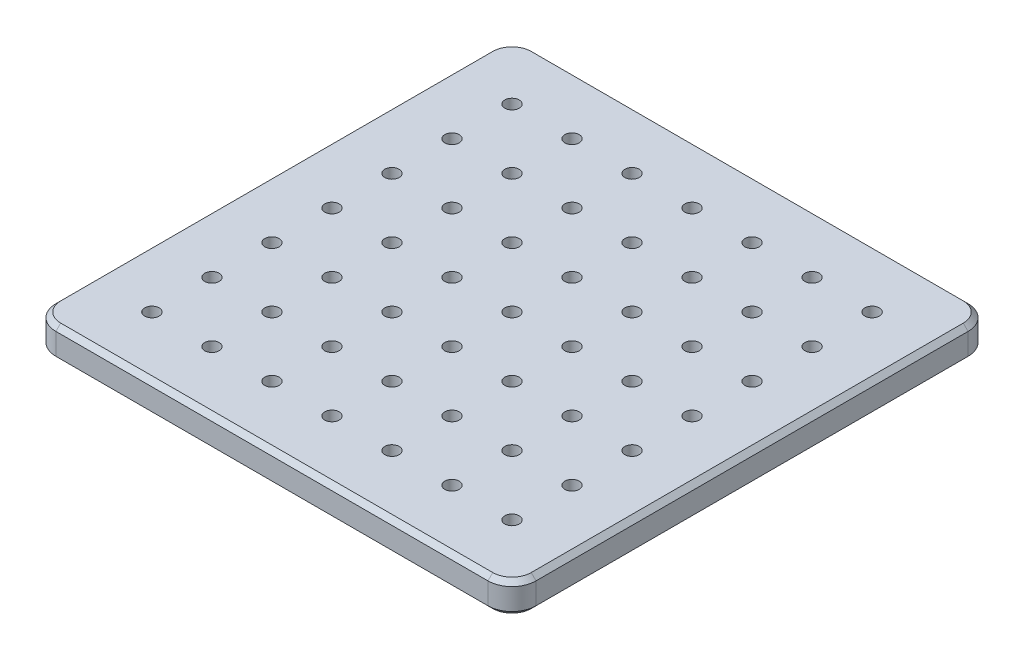
from build123d import *

# Parameters (mm, degrees)
SKETCH_1_R      = 3
EXTRUDE_1_DEPTH = 13
CHAMFER_1_SIZE  = 2


with BuildPart() as part:
    # 草图1 → 凸台-拉伸1 (new body)
    with BuildSketch(Plane(origin=(0, 0, 0), x_dir=(1, 0, 0), z_dir=(0, 1, 0))):
        with BuildLine():
            Line((-90, 100), (90, 100))
            ThreePointArc((90, 100), (97.071067812, 97.071067812), (100, 90))
            Line((100, 90), (100, -90))
            ThreePointArc((100, -90), (97.071067812, -97.071067812), (90, -100))
            Line((90, -100), (-90, -100))
            ThreePointArc((-90, -100), (-97.071067812, -97.071067812), (-100, -90))
            Line((-100, -90), (-100, 90))
            ThreePointArc((-100, 90), (-97.071067812, 97.071067812), (-90, 100))
        make_face()
        with Locations((-75, 75)):
            Circle(SKETCH_1_R, mode=Mode.SUBTRACT)
        with Locations((-50, 75)):
            Circle(SKETCH_1_R, mode=Mode.SUBTRACT)
        with Locations((-25, 75)):
            Circle(SKETCH_1_R, mode=Mode.SUBTRACT)
        with Locations((0, 75)):
            Circle(SKETCH_1_R, mode=Mode.SUBTRACT)
        with Locations((25, 75)):
            Circle(SKETCH_1_R, mode=Mode.SUBTRACT)
        with Locations((50, 75)):
            Circle(SKETCH_1_R, mode=Mode.SUBTRACT)
        with Locations((75, 75)):
            Circle(SKETCH_1_R, mode=Mode.SUBTRACT)
        with Locations((75, 50)):
            Circle(SKETCH_1_R, mode=Mode.SUBTRACT)
        with Locations((50, 50)):
            Circle(SKETCH_1_R, mode=Mode.SUBTRACT)
        with Locations((25, 50)):
            Circle(SKETCH_1_R, mode=Mode.SUBTRACT)
        with Locations((0, 50)):
            Circle(SKETCH_1_R, mode=Mode.SUBTRACT)
        with Locations((-25, 50)):
            Circle(SKETCH_1_R, mode=Mode.SUBTRACT)
        with Locations((-50, 50)):
            Circle(SKETCH_1_R, mode=Mode.SUBTRACT)
        with Locations((-75, 50)):
            Circle(SKETCH_1_R, mode=Mode.SUBTRACT)
        with Locations((75, 25)):
            Circle(SKETCH_1_R, mode=Mode.SUBTRACT)
        with Locations((50, 25)):
            Circle(SKETCH_1_R, mode=Mode.SUBTRACT)
        with Locations((25, 25)):
            Circle(SKETCH_1_R, mode=Mode.SUBTRACT)
        with Locations((0, 25)):
            Circle(SKETCH_1_R, mode=Mode.SUBTRACT)
        with Locations((-25, 25)):
            Circle(SKETCH_1_R, mode=Mode.SUBTRACT)
        with Locations((-50, 25)):
            Circle(SKETCH_1_R, mode=Mode.SUBTRACT)
        with Locations((-75, 25)):
            Circle(SKETCH_1_R, mode=Mode.SUBTRACT)
        with Locations((75, 0)):
            Circle(SKETCH_1_R, mode=Mode.SUBTRACT)
        with Locations((50, 0)):
            Circle(SKETCH_1_R, mode=Mode.SUBTRACT)
        with Locations((25, 0)):
            Circle(SKETCH_1_R, mode=Mode.SUBTRACT)
        Circle(SKETCH_1_R, mode=Mode.SUBTRACT)
        with Locations((-25, 0)):
            Circle(SKETCH_1_R, mode=Mode.SUBTRACT)
        with Locations((-50, 0)):
            Circle(SKETCH_1_R, mode=Mode.SUBTRACT)
        with Locations((-75, 0)):
            Circle(SKETCH_1_R, mode=Mode.SUBTRACT)
        with Locations((75, -25)):
            Circle(SKETCH_1_R, mode=Mode.SUBTRACT)
        with Locations((50, -25)):
            Circle(SKETCH_1_R, mode=Mode.SUBTRACT)
        with Locations((25, -25)):
            Circle(SKETCH_1_R, mode=Mode.SUBTRACT)
        with Locations((0, -25)):
            Circle(SKETCH_1_R, mode=Mode.SUBTRACT)
        with Locations((-25, -25)):
            Circle(SKETCH_1_R, mode=Mode.SUBTRACT)
        with Locations((-50, -25)):
            Circle(SKETCH_1_R, mode=Mode.SUBTRACT)
        with Locations((-75, -25)):
            Circle(SKETCH_1_R, mode=Mode.SUBTRACT)
        with Locations((75, -50)):
            Circle(SKETCH_1_R, mode=Mode.SUBTRACT)
        with Locations((50, -50)):
            Circle(SKETCH_1_R, mode=Mode.SUBTRACT)
        with Locations((25, -50)):
            Circle(SKETCH_1_R, mode=Mode.SUBTRACT)
        with Locations((0, -50)):
            Circle(SKETCH_1_R, mode=Mode.SUBTRACT)
        with Locations((-25, -50)):
            Circle(SKETCH_1_R, mode=Mode.SUBTRACT)
        with Locations((-50, -50)):
            Circle(SKETCH_1_R, mode=Mode.SUBTRACT)
        with Locations((-75, -50)):
            Circle(SKETCH_1_R, mode=Mode.SUBTRACT)
        with Locations((75, -75)):
            Circle(SKETCH_1_R, mode=Mode.SUBTRACT)
        with Locations((50, -75)):
            Circle(SKETCH_1_R, mode=Mode.SUBTRACT)
        with Locations((25, -75)):
            Circle(SKETCH_1_R, mode=Mode.SUBTRACT)
        with Locations((0, -75)):
            Circle(SKETCH_1_R, mode=Mode.SUBTRACT)
        with Locations((-25, -75)):
            Circle(SKETCH_1_R, mode=Mode.SUBTRACT)
        with Locations((-50, -75)):
            Circle(SKETCH_1_R, mode=Mode.SUBTRACT)
        with Locations((-75, -75)):
            Circle(SKETCH_1_R, mode=Mode.SUBTRACT)
    extrude(amount=EXTRUDE_1_DEPTH)

    # 倒角1
    chamfer_1_edges = [part.edges().sort_by_distance(p)[0] for p in [
        (0, 0, 100),
        (-97.071067812, 0, 97.071067812),
        (-100, 0, 0),
        (-97.071067812, 0, -97.071067812),
        (-97.071067812, 13, 97.071067812),
        (0, 13, 100),
        (97.071067812, 13, 97.071067812),
        (100, 13, 0),
        (97.071067812, 13, -97.071067812),
        (0, 13, -100),
        (-97.071067812, 13, -97.071067812),
        (0, 0, -100),
        (-100, 13, 0),
        (97.071067812, 0, -97.071067812),
        (100, 0, 0),
        (97.071067812, 0, 97.071067812),
    ]]
    chamfer(chamfer_1_edges, length=CHAMFER_1_SIZE)


solid = part.part
